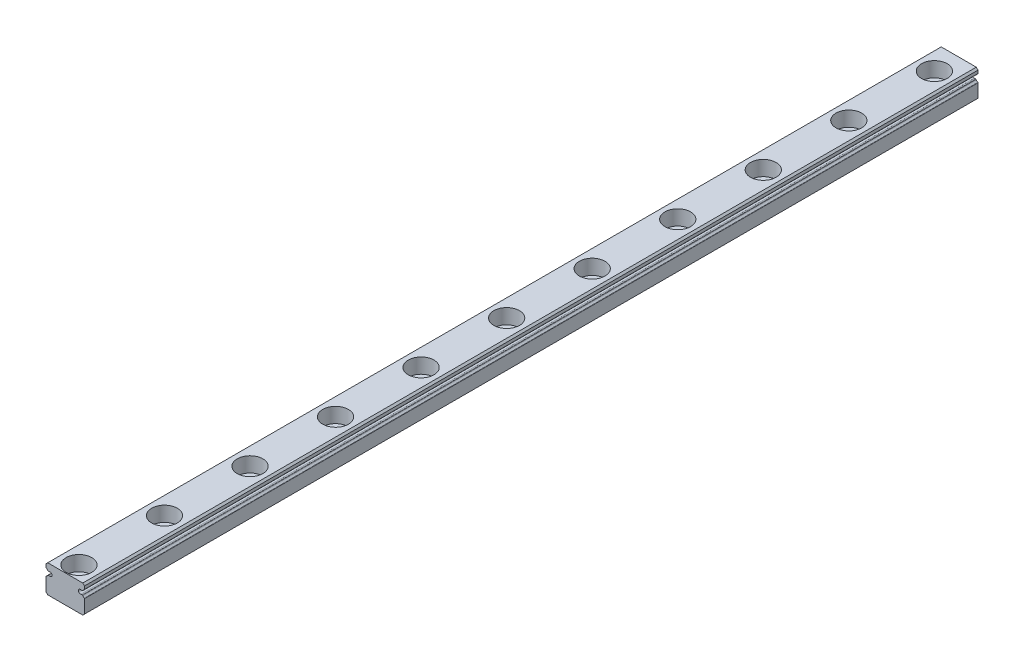
from build123d import *

# Parameters (mm, degrees)
BOSS_EXTRUDE1_DEPTH = 208.9
SKETCH2_R           = 3
CUT_EXTRUDE1_DEPTH  = 3.5
SKETCH3_R           = 1.75
CUT_EXTRUDE2_DEPTH  = 4


with BuildPart() as part:
    # Sketch1 → Boss-Extrude1 (new body)
    with BuildSketch(Plane.XY):
        with BuildLine():
            Line((-4.1, 6.5), (-4.5, 6.1))
            Line((-4.5, 6.1), (-4.5, 5.411997899))
            ThreePointArc((-4.5, 5.411997899), (-4.481535993, 5.345216747), (-4.431388889, 5.297405559))
            ThreePointArc((-4.431388889, 5.297405559), (-4.224528747, 5.147646302), (-4.065036084, 4.948194444))
            ThreePointArc((-4.065036084, 4.948194444), (-4.01760557, 4.901896679), (-3.953514706, 4.885))
            Line((-3.953514706, 4.885), (-3.688448805, 4.885))
            ThreePointArc((-3.688448805, 4.885), (-3.669364148, 4.886408492), (-3.650693039, 4.890603448))
            ThreePointArc((-3.650693039, 4.890603448), (-3.07, 4.46), (-3.650693039, 4.029396552))
            ThreePointArc((-3.650693039, 4.029396552), (-3.669364148, 4.033591508), (-3.688448805, 4.035))
            Line((-3.688448805, 4.035), (-3.953514706, 4.035))
            ThreePointArc((-3.953514706, 4.035), (-4.01760557, 4.018103321), (-4.065036084, 3.971805556))
            ThreePointArc((-4.065036084, 3.971805556), (-4.224528747, 3.772353698), (-4.431388889, 3.622594441))
            ThreePointArc((-4.431388889, 3.622594441), (-4.481535993, 3.574783253), (-4.5, 3.508002101))
            Line((-4.5, 3.508002101), (-4.5, 0.4))
            Line((-4.5, 0.4), (-4.1, 0))
            Line((-4.1, 0), (4.1, 0))
            Line((4.1, 0), (4.5, 0.4))
            Line((4.5, 0.4), (4.5, 3.508002101))
            ThreePointArc((4.5, 3.508002101), (4.481535993, 3.574783253), (4.431388889, 3.622594441))
            ThreePointArc((4.431388889, 3.622594441), (4.224528747, 3.772353698), (4.065036084, 3.971805556))
            ThreePointArc((4.065036084, 3.971805556), (4.01760557, 4.018103321), (3.953514706, 4.035))
            Line((3.953514706, 4.035), (3.688448805, 4.035))
            ThreePointArc((3.688448805, 4.035), (3.669364148, 4.033591508), (3.650693039, 4.029396552))
            ThreePointArc((3.650693039, 4.029396552), (3.07, 4.46), (3.650693039, 4.890603448))
            ThreePointArc((3.650693039, 4.890603448), (3.669364148, 4.886408492), (3.688448805, 4.885))
            Line((3.688448805, 4.885), (3.953514706, 4.885))
            ThreePointArc((3.953514706, 4.885), (4.01760557, 4.901896679), (4.065036084, 4.948194444))
            ThreePointArc((4.065036084, 4.948194444), (4.224528747, 5.147646302), (4.431388889, 5.297405559))
            ThreePointArc((4.431388889, 5.297405559), (4.481535993, 5.345216747), (4.5, 5.411997899))
            Line((4.5, 5.411997899), (4.5, 6.1))
            Line((4.5, 6.1), (4.1, 6.5))
            Line((4.1, 6.5), (-4.1, 6.5))
        make_face()
    extrude(amount=BOSS_EXTRUDE1_DEPTH)

    # Sketch2 → Cut-Extrude1 (cut)
    with BuildSketch(Plane(origin=(0, 6.5, 0), x_dir=(1, 0, 0), z_dir=(0, 1, 0))):
        with Locations((0, -205.7)):
            Circle(SKETCH2_R)
        with Locations((0, -185.7)):
            Circle(SKETCH2_R)
        with Locations((0, -165.7)):
            Circle(SKETCH2_R)
        with Locations((0, -145.7)):
            Circle(SKETCH2_R)
        with Locations((0, -125.7)):
            Circle(SKETCH2_R)
        with Locations((0, -105.7)):
            Circle(SKETCH2_R)
        with Locations((0, -85.7)):
            Circle(SKETCH2_R)
        with Locations((0, -65.7)):
            Circle(SKETCH2_R)
        with Locations((0, -45.7)):
            Circle(SKETCH2_R)
        with Locations((0, -25.7)):
            Circle(SKETCH2_R)
        with Locations((0, -5.7)):
            Circle(SKETCH2_R)
    extrude(amount=-CUT_EXTRUDE1_DEPTH, mode=Mode.SUBTRACT)

    # Sketch3 → Cut-Extrude2 (cut, through all)
    with BuildSketch(Plane(origin=(0, 3, 0), x_dir=(1, 0, 0), z_dir=(0, 1, 0))):
        with Locations((0, -205.7)):
            Circle(SKETCH3_R)
        with Locations((0, -185.7)):
            Circle(SKETCH3_R)
        with Locations((0, -165.7)):
            Circle(SKETCH3_R)
        with Locations((0, -145.7)):
            Circle(SKETCH3_R)
        with Locations((0, -125.7)):
            Circle(SKETCH3_R)
        with Locations((0, -105.7)):
            Circle(SKETCH3_R)
        with Locations((0, -85.7)):
            Circle(SKETCH3_R)
        with Locations((0, -65.7)):
            Circle(SKETCH3_R)
        with Locations((0, -45.7)):
            Circle(SKETCH3_R)
        with Locations((0, -25.7)):
            Circle(SKETCH3_R)
        with Locations((0, -5.7)):
            Circle(SKETCH3_R)
        with Locations((0, 14.3)):
            Circle(SKETCH3_R)
    extrude(amount=-CUT_EXTRUDE2_DEPTH, mode=Mode.SUBTRACT)


solid = part.part
